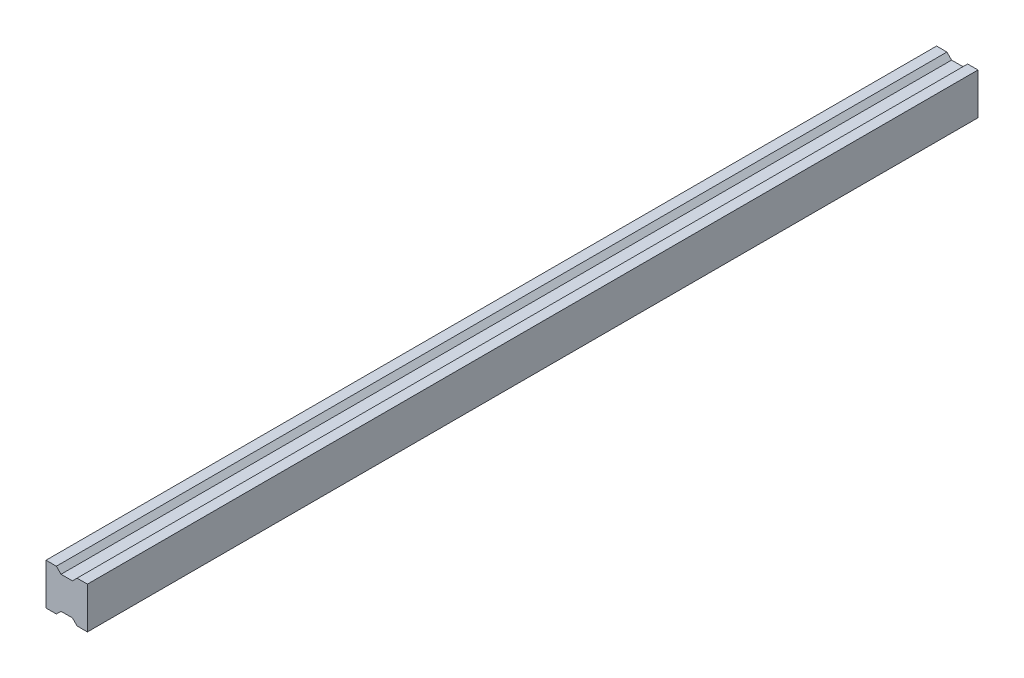
from build123d import *

# Parameters (mm, degrees)
BOSS_EXTRUDE1_DEPTH = 430


with BuildPart() as part:
    # Sketch1 → Boss-Extrude1 (new body)
    with BuildSketch(Plane.XY):
        Polygon((-2.750001757, -7.749999857), (2.749998624, -7.749999857), (4.999996165, -9.999997399), (9.999997037, -9.999997399), (9.999997037, 10.00000232), (4.999996165, 10.00000232), (2.749998624, 7.750004778), (-2.750001757, 7.750004778), (-4.999999298, 10.00000232), (-10.000000169, 10.00000232), (-10.000000169, -9.999997399), (-4.999999298, -9.999997399), align=None)
    extrude(amount=BOSS_EXTRUDE1_DEPTH)


solid = part.part
